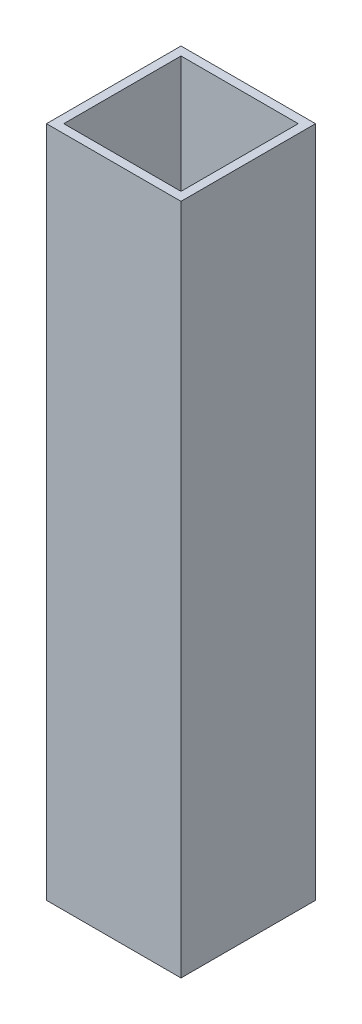
from build123d import *

# Parameters (mm, degrees)
SKETCH1_W           = 20
SKETCH1_H           = 20
SKETCH1_W_2         = 17.431674648
SKETCH1_H_2         = 17.431674648
BOSS_EXTRUDE1_DEPTH = 100


with BuildPart() as part:
    # Sketch1 → Boss-Extrude1 (new body)
    with BuildSketch(Plane(origin=(0, 0, 0), x_dir=(1, 0, 0), z_dir=(0, 1, 0))):
        Rectangle(SKETCH1_W, SKETCH1_H)
        Rectangle(SKETCH1_W_2, SKETCH1_H_2, mode=Mode.SUBTRACT)
    extrude(amount=BOSS_EXTRUDE1_DEPTH)


solid = part.part
